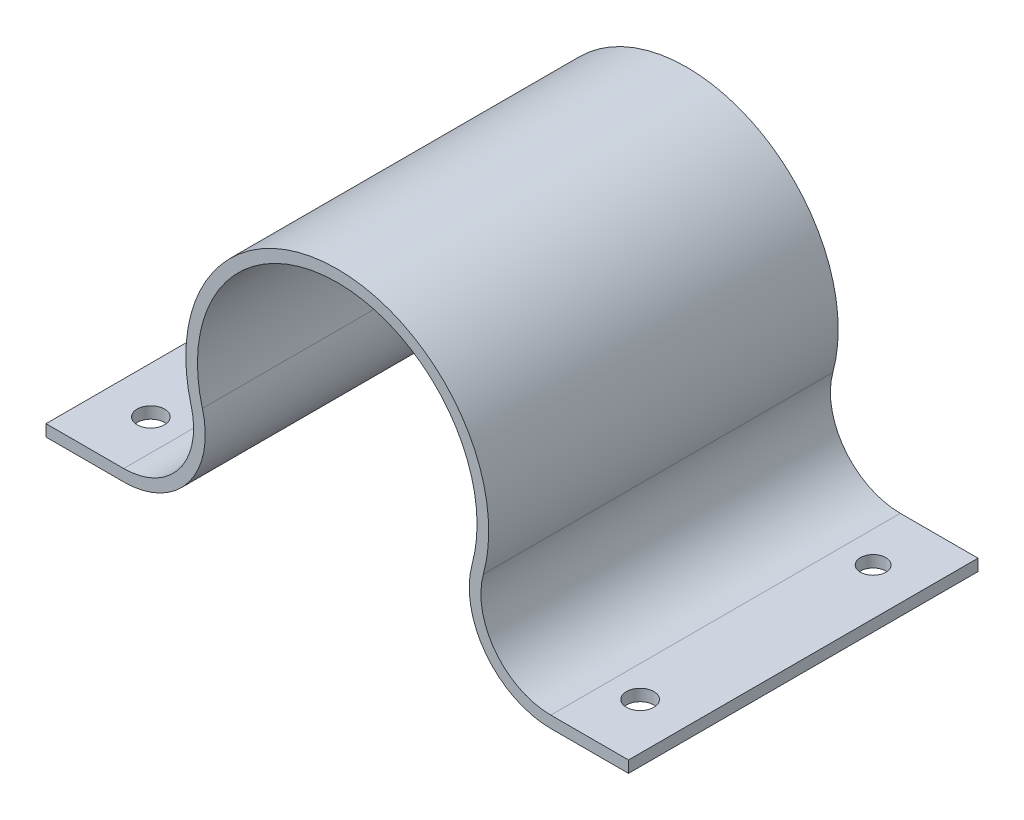
from build123d import *

# Parameters (mm, degrees)
BOSS_EXTRUDE1_DEPTH = 30
SKETCH2_R           = 1.089483659
SKETCH2_R_2         = 1.173994866
CUT_EXTRUDE1_DEPTH  = 15


with BuildPart() as part:
    # Sketch1 → Boss-Extrude1 (new body)
    with BuildSketch(Plane.XY):
        with BuildLine():
            Line((-25, -12), (-18.33030278, -12))
            ThreePointArc((-18.33030278, -12), (-12.76726688, -9.248838851), (-11.577033335, -3.157894737))
            ThreePointArc((-11.577033335, -3.157894737), (0, 12), (11.577033335, -3.157894737))
            ThreePointArc((11.577033335, -3.157894737), (12.76726688, -9.248838851), (18.33030278, -12))
            Line((18.33030278, -12), (25, -12))
            Line((25, -12), (25, -11))
            Line((25, -11), (18.33030278, -11))
            ThreePointArc((18.33030278, -11), (13.561986294, -8.641861872), (12.541786113, -3.421052632))
            ThreePointArc((12.541786113, -3.421052632), (0, 13), (-12.541786113, -3.421052632))
            ThreePointArc((-12.541786113, -3.421052632), (-13.561986294, -8.641861872), (-18.33030278, -11))
            Line((-18.33030278, -11), (-25, -11))
            Line((-25, -11), (-25, -12))
        make_face()
    extrude(amount=BOSS_EXTRUDE1_DEPTH)

    # Sketch2 → Cut-Extrude1 (cut)
    with BuildSketch(Plane(origin=(0, -11, 0), x_dir=(1, 0, 0), z_dir=(0, 1, 0))):
        with Locations((21, -5)):
            Circle(SKETCH2_R)
        with Locations((21, -25)):
            Circle(SKETCH2_R_2)
    cut_extrude1 = extrude(amount=-CUT_EXTRUDE1_DEPTH, mode=Mode.SUBTRACT)

    # Mirror1: Cut-Extrude1 across plane
    add(cut_extrude1.mirror(Plane(origin=(0, 0, 0), x_dir=(0, 0, 1), z_dir=(1, 0, 0))), mode=Mode.SUBTRACT)


solid = part.part
